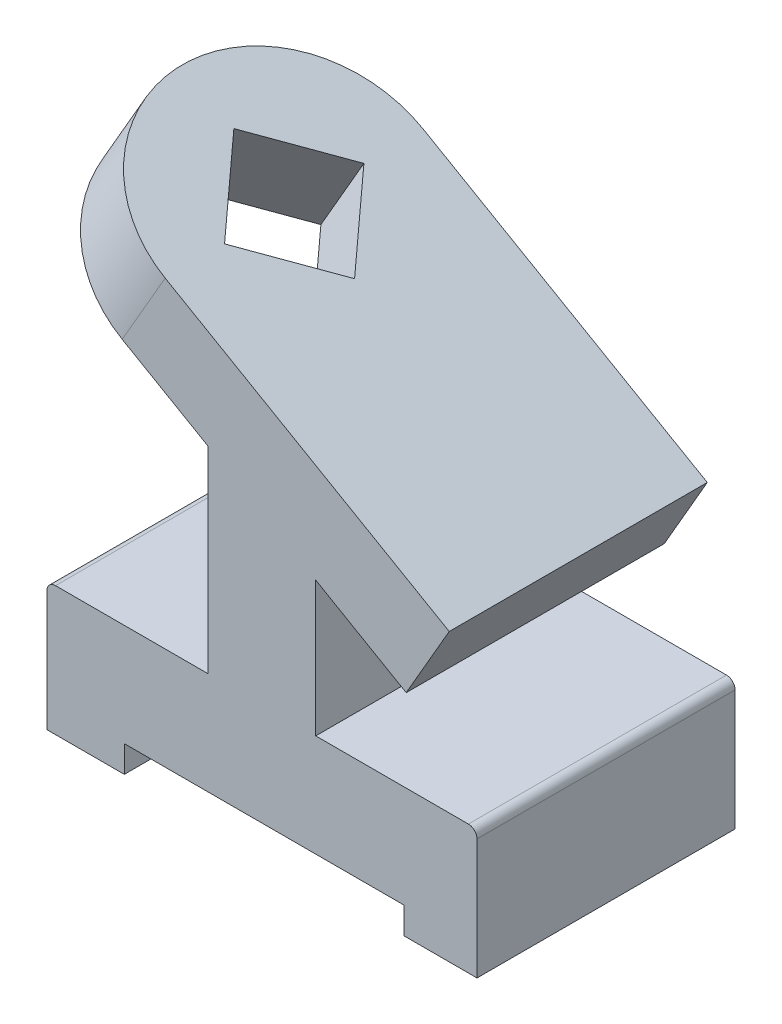
from build123d import *

# Parameters (mm, degrees)
BOSS_EXTRUDE1_DEPTH      = 38.1
BOSS_EXTRUDE1_DEPTH_BACK = 38.1
FILLET3_R                = 2.54
FILLET4_R                = 2.54
BOSS_EXTRUDE2_DEPTH      = 76.2
SKETCH6_R                = 38.1
BOSS_EXTRUDE3_DEPTH      = 25.4
CUT_EXTRUDE2_DEPTH       = 141.480169548


with BuildPart() as part:
    # Sketch1 → Boss-Extrude1 (new, two sides: drawn at the far end of the back side and taken through both)
    with BuildSketch(Plane.XY.offset(-BOSS_EXTRUDE1_DEPTH_BACK)):
        Polygon((-78.057486297, 0), (-30.432486297, 0), (-30.432486297, 58.166), (1.317513703, 58.166), (1.317513703, 0), (48.942513703, 0), (48.942513703, -38.1), (27.352513703, -38.1), (27.352513703, -30.236305156), (-55.197486297, -30.236305156), (-55.197486297, -38.1), (-78.057486297, -38.1), align=None)
    extrude(amount=BOSS_EXTRUDE1_DEPTH + BOSS_EXTRUDE1_DEPTH_BACK)

    # Fillet3
    fillet3_edges = [part.edges().sort_by_distance(p)[0] for p in [
        (48.942513703, 0, 0),
    ]]
    fillet(fillet3_edges, radius=FILLET3_R)

    # Fillet4
    fillet4_edges = [part.edges().sort_by_distance(p)[0] for p in [
        (-78.057486297, 0, 0),
    ]]
    fillet(fillet4_edges, radius=FILLET4_R)

    # Sketch5 → Boss-Extrude2 (add)
    with BuildSketch(Plane.XY.offset(38.1)):
        Polygon((-55.832486297, 72.830696837), (28.031248742, 24.411946837), (40.731248742, 46.408992094), (-43.132486297, 94.827742094), align=None)
    extrude(amount=-BOSS_EXTRUDE2_DEPTH)

    # Sketch6 → Boss-Extrude3 (add)
    with BuildSketch(Plane(origin=(30.278495244, 52.443892139, 0), x_dir=(0.8660254037844386, -0.5000000000000001, 0), z_dir=(0.5000000000000001, 0.8660254037844386, 0))):
        with Locations((-84.767699909, 0)):
            Circle(SKETCH6_R)
    extrude(amount=-BOSS_EXTRUDE3_DEPTH)

    # Sketch7 → Cut-Extrude2 (cut, through all)
    with BuildSketch(Plane(origin=(17.578495244, 30.446846883, 0), x_dir=(-0.8660254037844386, 0.5000000000000001, 0), z_dir=(-0.5000000000000001, -0.8660254037844386, 0))):
        Polygon((84.767699909, 20.574), (105.341699909, 0), (84.767699909, -20.574), (64.193699909, 0), align=None)
    extrude(amount=-CUT_EXTRUDE2_DEPTH, mode=Mode.SUBTRACT)


solid = part.part
